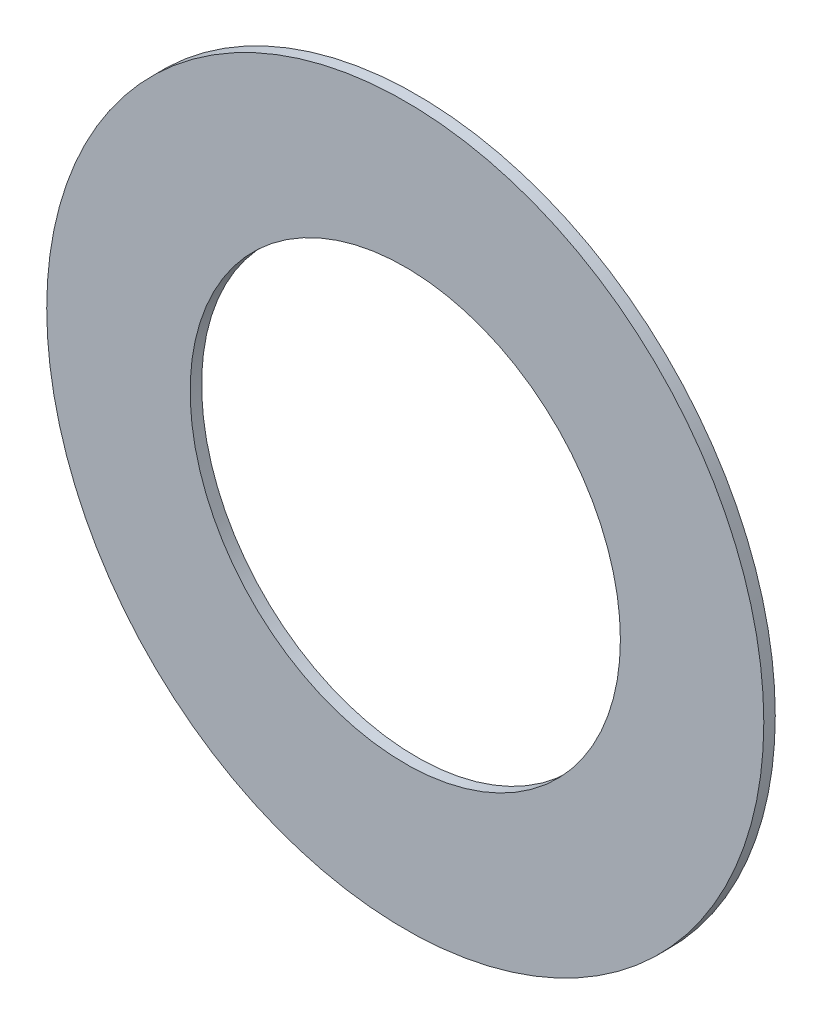
from build123d import *

# Parameters (mm, degrees)
SKETCH1_R           = 7.9375
SKETCH1_R_2         = 4.7625
BOSS_EXTRUDE1_DEPTH = 0.254


with BuildPart() as part:
    # Sketch1 → Boss-Extrude1 (new body)
    with BuildSketch(Plane.XY):
        Circle(SKETCH1_R)
        Circle(SKETCH1_R_2, mode=Mode.SUBTRACT)
    extrude(amount=BOSS_EXTRUDE1_DEPTH)


solid = part.part
